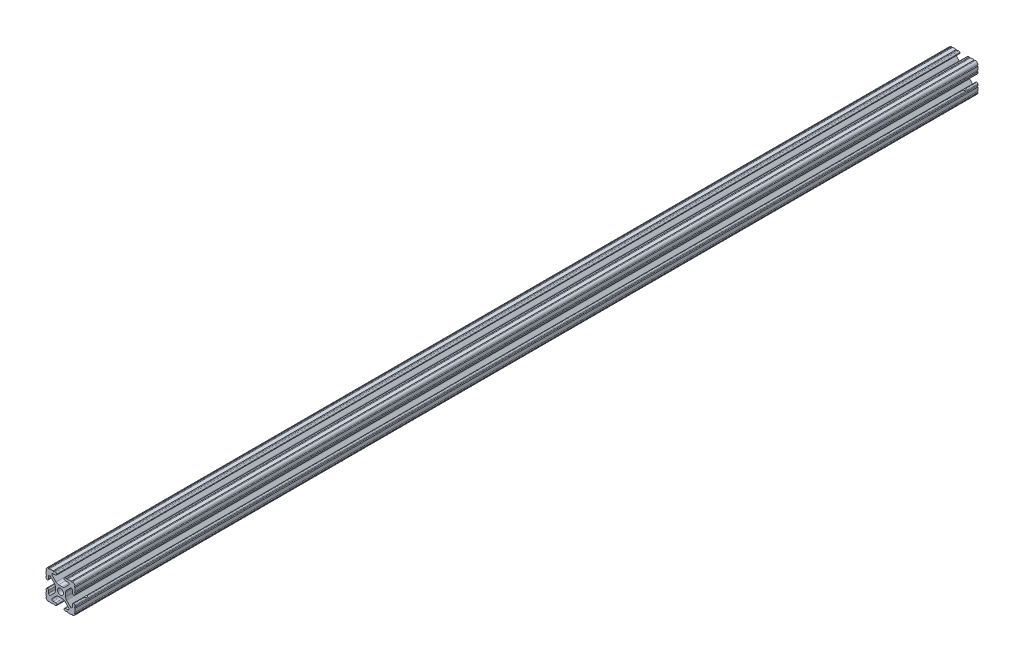
from build123d import *

# Parameters (mm, degrees)
SKETCH1_R               = 2.6035
BOSS_EXTRUDE1_DEPTH     = 396.735
SKETCH2_R               = 3.5
CUT_EXTRUDE1_DEPTH      = 9.1915
CUT_EXTRUDE1_DEPTH_BACK = 18.2085


with BuildPart() as part:
    # Sketch1 → Boss-Extrude1 (new body, symmetric)
    with BuildSketch(Plane.XY):
        with BuildLine():
            Line((-7.179650497, -8.645192506), (-3.952270251, -5.423690499))
            ThreePointArc((-3.952270251, -5.423690499), (-2.922936451, -4.736929036), (-1.709253557, -4.4958))
            Line((-1.709253557, -4.4958), (1.709253557, -4.4958))
            ThreePointArc((1.709253557, -4.4958), (2.922936451, -4.736929036), (3.952270251, -5.423690499))
            Line((3.952270251, -5.423690499), (7.179650497, -8.645192506))
            ThreePointArc((7.179650497, -8.645192506), (7.41473083, -9.822813117), (6.416408329, -10.4902))
            Line((6.416408329, -10.4902), (4.287512407, -10.4902))
            ThreePointArc((4.287512407, -10.4902), (3.54574862, -10.79744862), (3.2385, -11.539212407))
            Line((3.2385, -11.539212407), (3.2385, -11.650987593))
            ThreePointArc((3.2385, -11.650987593), (3.54574862, -12.39275138), (4.287512407, -12.7))
            Line((4.287512407, -12.7), (5.317126718, -12.7))
            ThreePointArc((5.317126718, -12.7), (5.825126718, -12.192), (6.333126718, -12.7))
            Line((6.333126718, -12.7), (9.550443118, -12.7))
            ThreePointArc((9.550443118, -12.7), (10.058366869, -12.192000006), (10.566443095, -12.699847501))
            ThreePointArc((10.566443095, -12.699847501), (12.082537762, -12.08250727), (12.699846982, -10.566399977))
            ThreePointArc((12.699846982, -10.566399977), (12.192000006, -10.058323491), (12.7, -9.5504))
            Line((12.7, -9.5504), (12.7, -6.3330836))
            ThreePointArc((12.7, -6.3330836), (12.192, -5.8250836), (12.7, -5.3170836))
            Line((12.7, -5.3170836), (12.7, -4.287469289))
            ThreePointArc((12.7, -4.287469289), (12.39275138, -3.545705502), (11.650987593, -3.238456882))
            Line((11.650987593, -3.238456882), (11.539212407, -3.238456882))
            ThreePointArc((11.539212407, -3.238456882), (10.79744862, -3.545705502), (10.4902, -4.287469289))
            Line((10.4902, -4.287469289), (10.4902, -6.402089023))
            ThreePointArc((10.4902, -6.402089023), (9.856505071, -7.351067942), (8.737131347, -7.129408934))
            Line((8.737131347, -7.129408934), (5.441005833, -3.840816462))
            ThreePointArc((5.441005833, -3.840816462), (4.750877967, -2.809883091), (4.5085, -1.593185507))
            Line((4.5085, -1.593185507), (4.5085, 1.593185507))
            ThreePointArc((4.5085, 1.593185507), (4.750877967, 2.809883091), (5.441005833, 3.840816462))
            Line((5.441005833, 3.840816462), (8.737131347, 7.129408934))
            ThreePointArc((8.737131347, 7.129408934), (9.856505071, 7.351067942), (10.4902, 6.402089023))
            Line((10.4902, 6.402089023), (10.4902, 4.287469289))
            ThreePointArc((10.4902, 4.287469289), (10.79744862, 3.545705502), (11.539212407, 3.238456882))
            Line((11.539212407, 3.238456882), (11.650987593, 3.238456882))
            ThreePointArc((11.650987593, 3.238456882), (12.39275138, 3.545705502), (12.7, 4.287469289))
            Line((12.7, 4.287469289), (12.7, 5.3170836))
            ThreePointArc((12.7, 5.3170836), (12.192, 5.8250836), (12.7, 6.3330836))
            Line((12.7, 6.3330836), (12.7, 9.5504))
            ThreePointArc((12.7, 9.5504), (12.192000006, 10.058323491), (12.699846982, 10.566399977))
            ThreePointArc((12.699846982, 10.566399977), (12.082537762, 12.08250727), (10.566443095, 12.699847501))
            ThreePointArc((10.566443095, 12.699847501), (10.058366869, 12.192000006), (9.550443118, 12.7))
            Line((9.550443118, 12.7), (6.333126718, 12.7))
            ThreePointArc((6.333126718, 12.7), (5.825126718, 12.192), (5.317126718, 12.7))
            Line((5.317126718, 12.7), (4.287512407, 12.7))
            ThreePointArc((4.287512407, 12.7), (3.54574862, 12.39275138), (3.2385, 11.650987593))
            Line((3.2385, 11.650987593), (3.2385, 11.539212407))
            ThreePointArc((3.2385, 11.539212407), (3.54574862, 10.79744862), (4.287512407, 10.4902))
            Line((4.287512407, 10.4902), (6.476788598, 10.4902))
            ThreePointArc((6.476788598, 10.4902), (7.432222385, 9.85140422), (7.207036008, 8.724370562))
            Line((7.207036008, 8.724370562), (3.898272566, 5.423169045))
            ThreePointArc((3.898272566, 5.423169045), (2.869120213, 4.736787962), (1.655778399, 4.4958))
            Line((1.655778399, 4.4958), (-1.655778399, 4.4958))
            ThreePointArc((-1.655778399, 4.4958), (-2.869120213, 4.736787962), (-3.898272566, 5.423169045))
            Line((-3.898272566, 5.423169045), (-7.207036008, 8.724370562))
            ThreePointArc((-7.207036008, 8.724370562), (-7.432222385, 9.85140422), (-6.476788598, 10.4902))
            Line((-6.476788598, 10.4902), (-4.287512407, 10.4902))
            ThreePointArc((-4.287512407, 10.4902), (-3.54574862, 10.79744862), (-3.2385, 11.539212407))
            Line((-3.2385, 11.539212407), (-3.2385, 11.650987593))
            ThreePointArc((-3.2385, 11.650987593), (-3.54574862, 12.39275138), (-4.287512407, 12.7))
            Line((-4.287512407, 12.7), (-5.317126718, 12.7))
            ThreePointArc((-5.317126718, 12.7), (-5.825126718, 12.192), (-6.333126718, 12.7))
            Line((-6.333126718, 12.7), (-9.550443118, 12.7))
            ThreePointArc((-9.550443118, 12.7), (-10.058366869, 12.192000006), (-10.566443095, 12.699847501))
            ThreePointArc((-10.566443095, 12.699847501), (-12.082537762, 12.08250727), (-12.699846982, 10.566399977))
            ThreePointArc((-12.699846982, 10.566399977), (-12.192000006, 10.058323491), (-12.7, 9.5504))
            Line((-12.7, 9.5504), (-12.7, 6.3330836))
            ThreePointArc((-12.7, 6.3330836), (-12.192, 5.8250836), (-12.7, 5.3170836))
            Line((-12.7, 5.3170836), (-12.7, 4.287469289))
            ThreePointArc((-12.7, 4.287469289), (-12.39275138, 3.545705502), (-11.650987593, 3.238456882))
            Line((-11.650987593, 3.238456882), (-11.539212407, 3.238456882))
            ThreePointArc((-11.539212407, 3.238456882), (-10.79744862, 3.545705502), (-10.4902, 4.287469289))
            Line((-10.4902, 4.287469289), (-10.4902, 6.402089023))
            ThreePointArc((-10.4902, 6.402089023), (-9.856505071, 7.351067942), (-8.737131347, 7.129408934))
            Line((-8.737131347, 7.129408934), (-5.441005833, 3.840816462))
            ThreePointArc((-5.441005833, 3.840816462), (-4.750877967, 2.809883091), (-4.5085, 1.593185507))
            Line((-4.5085, 1.593185507), (-4.5085, -1.593185507))
            ThreePointArc((-4.5085, -1.593185507), (-4.750877967, -2.809883091), (-5.441005833, -3.840816462))
            Line((-5.441005833, -3.840816462), (-8.737131347, -7.129408934))
            ThreePointArc((-8.737131347, -7.129408934), (-9.856505071, -7.351067942), (-10.4902, -6.402089023))
            Line((-10.4902, -6.402089023), (-10.4902, -4.287469289))
            ThreePointArc((-10.4902, -4.287469289), (-10.79744862, -3.545705502), (-11.539212407, -3.238456882))
            Line((-11.539212407, -3.238456882), (-11.650987593, -3.238456882))
            ThreePointArc((-11.650987593, -3.238456882), (-12.39275138, -3.545705502), (-12.7, -4.287469289))
            Line((-12.7, -4.287469289), (-12.7, -5.3170836))
            ThreePointArc((-12.7, -5.3170836), (-12.192, -5.8250836), (-12.7, -6.3330836))
            Line((-12.7, -6.3330836), (-12.7, -9.5504))
            ThreePointArc((-12.7, -9.5504), (-12.192000006, -10.058323491), (-12.699846982, -10.566399977))
            ThreePointArc((-12.699846982, -10.566399977), (-12.082537762, -12.08250727), (-10.566443095, -12.699847501))
            ThreePointArc((-10.566443095, -12.699847501), (-10.058366869, -12.192000006), (-9.550443118, -12.7))
            Line((-9.550443118, -12.7), (-6.333126718, -12.7))
            ThreePointArc((-6.333126718, -12.7), (-5.825126718, -12.192), (-5.317126718, -12.7))
            Line((-5.317126718, -12.7), (-4.287512407, -12.7))
            ThreePointArc((-4.287512407, -12.7), (-3.54574862, -12.39275138), (-3.2385, -11.650987593))
            Line((-3.2385, -11.650987593), (-3.2385, -11.539212407))
            ThreePointArc((-3.2385, -11.539212407), (-3.54574862, -10.79744862), (-4.287512407, -10.4902))
            Line((-4.287512407, -10.4902), (-6.416408329, -10.4902))
            ThreePointArc((-6.416408329, -10.4902), (-7.41473083, -9.822813117), (-7.179650497, -8.645192506))
        make_face()
        Circle(SKETCH1_R, mode=Mode.SUBTRACT)
    extrude(amount=BOSS_EXTRUDE1_DEPTH, both=True)

    # Sketch2 → Cut-Extrude1 (cut, two sides)
    with BuildSketch(Plane(origin=(4.5085, 0, 0), x_dir=(0, 0, -1), z_dir=(1, 0, 0))) as cut_extrude1_sk:
        with Locations((-386.035, 0)):
            Circle(SKETCH2_R)
        with Locations((386.035, 0)):
            Circle(SKETCH2_R)
    extrude(amount=CUT_EXTRUDE1_DEPTH, mode=Mode.SUBTRACT)
    extrude(cut_extrude1_sk.sketch, amount=-CUT_EXTRUDE1_DEPTH_BACK, mode=Mode.SUBTRACT)


solid = part.part
